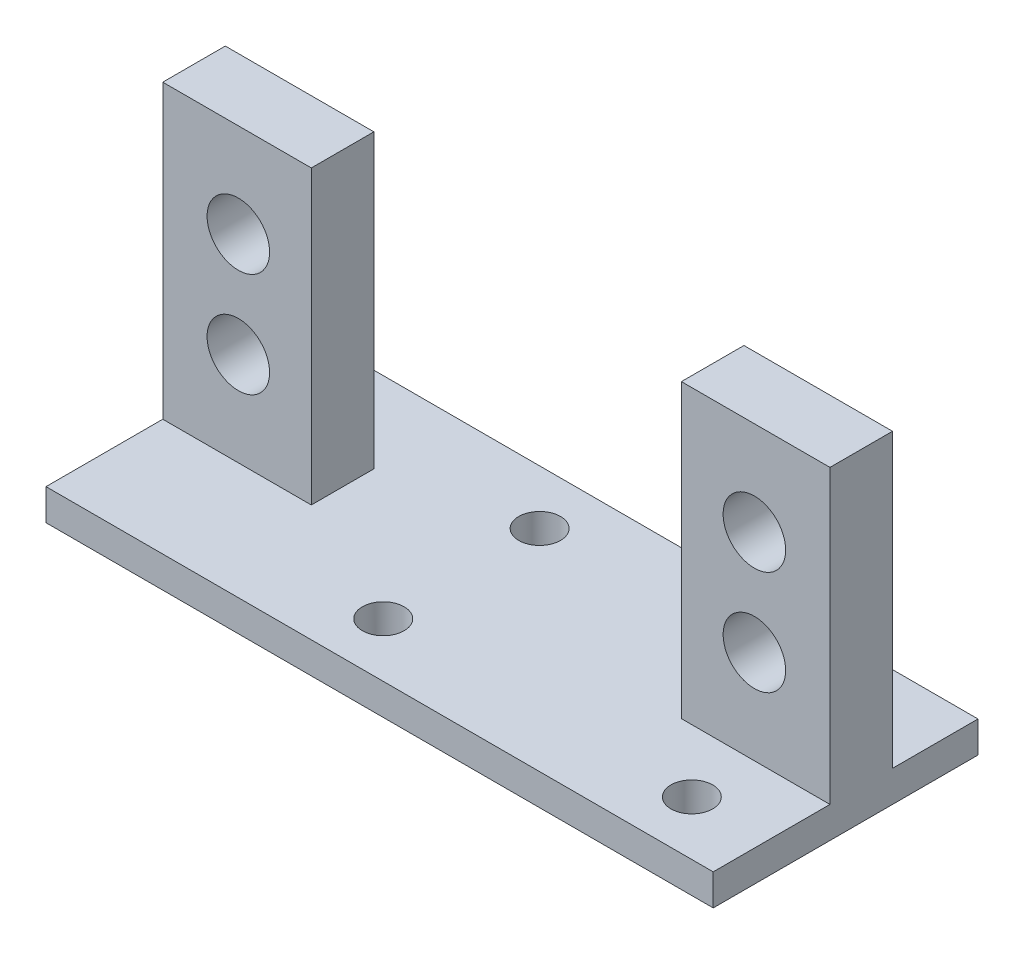
from build123d import *
from build123d.topology import SkipClean

# Parameters (mm, degrees)
SKETCH_1_W          = 58
SKETCH_1_H          = 25.4
EXTRUDE_1_DEPTH     = 3
SKETCH_2_W          = 8
SKETCH_2_H          = 3
EXTRUDE_2_DEPTH     = 28
SKETCH_3_R          = 3
CUT_EXTRUDE_1_DEPTH = 12
SKETCH_4_R          = 2
CUT_EXTRUDE_2_DEPTH = 22
SKETCH_5_W          = 8
SKETCH_5_H          = 3
CUT_EXTRUDE_3_DEPTH = 28
SKETCH_6_W          = 8
SKETCH_6_H          = 28
SKETCH_6_R          = 3
EXTRUDE_3_DEPTH     = 3
SKETCH_7_W          = 6
SKETCH_7_H          = 28
EXTRUDE_4_DEPTH     = 3
SKETCH_8_W          = 6
SKETCH_8_H          = 28
EXTRUDE_5_DEPTH     = 3
SKETCH_9_W          = 6
SKETCH_9_H          = 28
EXTRUDE_6_DEPTH     = 0.25
SKETCH_10_W         = 6
SKETCH_10_H         = 28
EXTRUDE_7_DEPTH     = 0.25
EXTRUDE_8_DEPTH     = 3
EXTRUDE_9_DEPTH     = 3


with BuildPart() as part:
    # 草图1 → 凸台-拉伸1 (new body)
    with BuildSketch(Plane(origin=(0, 0, 0), x_dir=(1, 0, 0), z_dir=(0, 1, 0))):
        Rectangle(SKETCH_1_W, SKETCH_1_H)
    extrude(amount=EXTRUDE_1_DEPTH)

    # 草图2 → 凸台-拉伸2 (add)
    with BuildSketch(Plane(origin=(0, 3, 0), x_dir=(1, 0, 0), z_dir=(0, 1, 0))):
        with Locations((-24.75, 11.2)):
            Rectangle(SKETCH_2_W, SKETCH_2_H)
        with Locations((24.75, 11.2)):
            Rectangle(SKETCH_2_W, SKETCH_2_H)
        with Locations((-24.75, 0)):
            Rectangle(SKETCH_2_W, SKETCH_2_H)
        with Locations((24.75, 0)):
            Rectangle(SKETCH_2_W, SKETCH_2_H)
    extrude(amount=EXTRUDE_2_DEPTH)

    # 草图3 → 切除-拉伸1 (cut, symmetric)
    with BuildSketch(Plane.XY.offset(-9.7)):
        with Locations((-24.75, 12)):
            Circle(SKETCH_3_R)
        with Locations((-24.75, 22)):
            Circle(SKETCH_3_R)
        with Locations((24.75, 12)):
            Circle(SKETCH_3_R)
        with Locations((24.75, 22)):
            Circle(SKETCH_3_R)
    extrude(amount=CUT_EXTRUDE_1_DEPTH, both=True, mode=Mode.SUBTRACT)

    # 草图4 → 切除-拉伸2 (cut)
    with BuildSketch(Plane(origin=(0, 3, 0), x_dir=(1, 0, 0), z_dir=(0, 1, 0))):
        with Locations(Location((24.75, -7.5, 0), (0, 0, 270))):
            Circle(SKETCH_4_R)
        with Locations(Location((24.75, 7.5, 0), (0, 0, 270))):
            Circle(SKETCH_4_R)
        with Locations(Location((-4.85, 7.5, 0), (0, 0, 270))):
            Circle(SKETCH_4_R)
        with Locations(Location((-4.85, -7.5, 0), (0, 0, 270))):
            Circle(SKETCH_4_R)
    extrude(amount=-CUT_EXTRUDE_2_DEPTH, mode=Mode.SUBTRACT)

    # 草图5 → 切除-拉伸3 (cut)
    with BuildSketch(Plane(origin=(0, 31, 0), x_dir=(1, 0, 0), z_dir=(0, 1, 0))):
        with Locations((-24.75, 11.2)):
            Rectangle(SKETCH_5_W, SKETCH_5_H)
        with Locations((24.75, 11.2)):
            Rectangle(SKETCH_5_W, SKETCH_5_H)
    extrude(amount=-CUT_EXTRUDE_3_DEPTH, mode=Mode.SUBTRACT)

    # 草图6 → 凸台-拉伸3 (add)
    # profile 1 of 2: a face of its own
    with SkipClean():  # the faces are left unmerged after this step: merging them gives an invalid solid
        with BuildSketch(Plane(origin=(0, 0, -1.5), x_dir=(-1, 0, 0), z_dir=(0, 0, -1))):
            with Locations((-24.75, 17)):
                Rectangle(SKETCH_6_W, SKETCH_6_H)
            with Locations((-24.75, 22)):
                Circle(SKETCH_6_R, mode=Mode.SUBTRACT)
            with Locations((-24.75, 12)):
                Circle(SKETCH_6_R, mode=Mode.SUBTRACT)
        # profile 2 of 2: a face of its own
        with BuildSketch(Plane(origin=(0, 0, -1.5), x_dir=(-1, 0, 0), z_dir=(0, 0, -1))):
            with Locations((24.75, 17)):
                Rectangle(SKETCH_6_W, SKETCH_6_H)
            with Locations((24.75, 22)):
                Circle(SKETCH_6_R, mode=Mode.SUBTRACT)
            with Locations((24.75, 12)):
                Circle(SKETCH_6_R, mode=Mode.SUBTRACT)
        extrude(amount=EXTRUDE_3_DEPTH)

    # 草图7 → 凸台-拉伸4 (add)
    with SkipClean():  # the faces are left unmerged after this step: merging them gives an invalid solid
        with BuildSketch(Plane.ZY.offset(-20.75)):
            with Locations((-1.5, 17)):
                Rectangle(SKETCH_7_W, SKETCH_7_H)
        extrude(amount=EXTRUDE_4_DEPTH)

    # 草图8 → 凸台-拉伸5 (add)
    with SkipClean():  # the faces are left unmerged after this step: merging them gives an invalid solid
        with BuildSketch(Plane(origin=(-20.75, 0, 0), x_dir=(0, 0, -1), z_dir=(1, 0, 0))):
            with Locations((1.5, 17)):
                Rectangle(SKETCH_8_W, SKETCH_8_H)
        extrude(amount=EXTRUDE_5_DEPTH)

    # 草图9 → 凸台-拉伸6 (add)
    with SkipClean():  # the faces are left unmerged after this step: merging them gives an invalid solid
        with BuildSketch(Plane(origin=(28.75, 0, 0), x_dir=(0, 0, -1), z_dir=(1, 0, 0))):
            with Locations((1.5, 17)):
                Rectangle(SKETCH_9_W, SKETCH_9_H)
        extrude(amount=EXTRUDE_6_DEPTH)

    # 草图10 → 凸台-拉伸7 (add)
    with SkipClean():  # the faces are left unmerged after this step: merging them gives an invalid solid
        with BuildSketch(Plane.ZY.offset(28.75)):
            with Locations((-1.5, 17)):
                Rectangle(SKETCH_10_W, SKETCH_10_H)
        extrude(amount=EXTRUDE_7_DEPTH)

    # 草图11 → 凸台-拉伸8 (add)
    with SkipClean():  # the faces are left unmerged after this step: merging them gives an invalid solid
        with BuildSketch(Plane.ZY.offset(29)):
            Polygon((-4.5, 31), (1.5, 31), (1.5, 3), (12.7, 3), (12.7, 0), (-12.7, 0), (-12.7, 3), (-4.5, 3), align=None)
        extrude(amount=EXTRUDE_8_DEPTH)

    # 草图12 → 凸台-拉伸9 (add)
    with SkipClean():  # the faces are left unmerged after this step: merging them gives an invalid solid
        with BuildSketch(Plane(origin=(29, 0, 0), x_dir=(0, 0, -1), z_dir=(1, 0, 0))):
            Polygon((-1.5, 31), (4.5, 31), (4.5, 3), (12.7, 3), (12.7, 0), (-12.7, 0), (-12.7, 3), (-1.5, 3), align=None)
        extrude(amount=EXTRUDE_9_DEPTH)


solid = part.part
